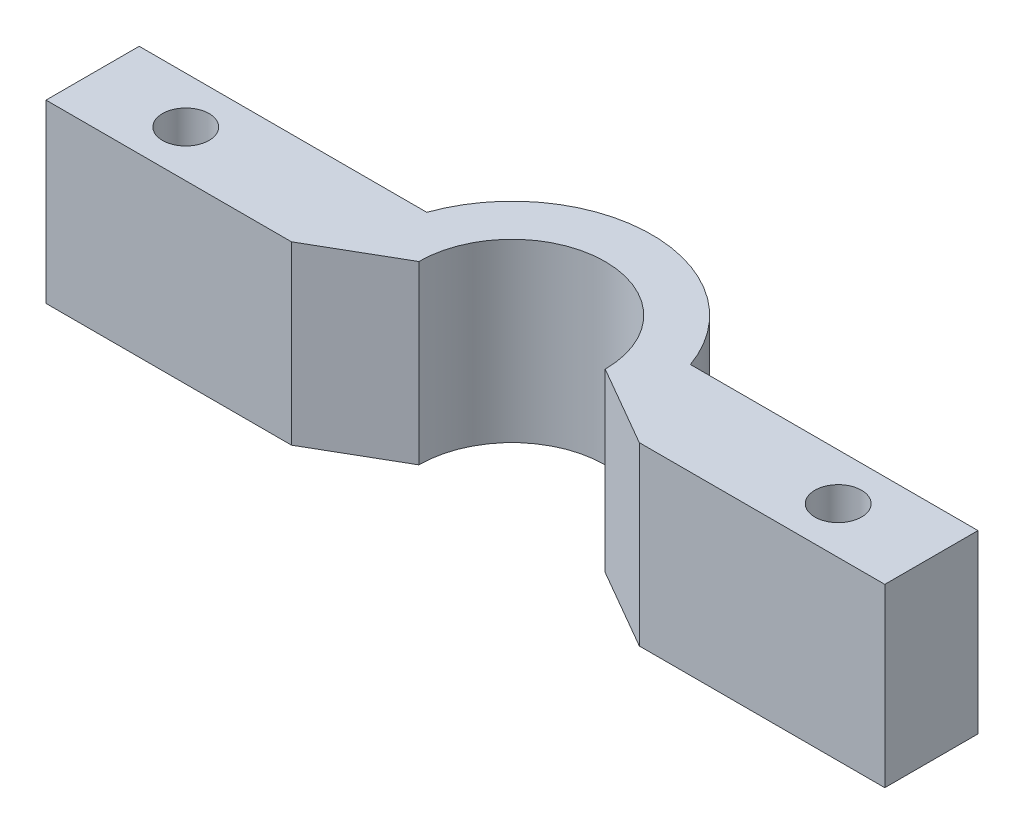
from build123d import *

# Parameters (mm, degrees)
SKETCH1_R           = 0.79375
BOSS_EXTRUDE1_DEPTH = 3


with BuildPart() as part:
    # Sketch1 → Boss-Extrude1 (new body, symmetric)
    with BuildSketch(Plane(origin=(0, 0, 0), x_dir=(1, 0, 0), z_dir=(0, 1, 0))):
        with BuildLine():
            ThreePointArc((-4.682314967, -0.870248702), (-4.742411374, -0.436967517), (-4.7625, 0))
            ThreePointArc((-4.7625, 0), (-4.69391314, 0.805348174), (-4.490128061, 1.5875))
            Line((-4.490128061, 1.5875), (-14.2875, 1.5875))
            Line((-14.2875, 1.5875), (-14.2875, -1.5875))
            Line((-14.2875, -1.5875), (-5.924630657, -1.5875))
            Line((-5.924630657, -1.5875), (-4.682314967, -0.870248702))
        make_face()
        with Locations((-11.1125, 0)):
            Circle(SKETCH1_R, mode=Mode.SUBTRACT)
        with BuildLine():
            Line((-4.7625, 0), (-3.175, 0))
            ThreePointArc((-3.175, 0), (-3.066814498, 0.821750468), (-2.749630657, 1.5875))
            Line((-2.749630657, 1.5875), (-4.490128061, 1.5875))
            ThreePointArc((-4.490128061, 1.5875), (-4.69391314, 0.805348174), (-4.7625, 0))
        make_face()
        with BuildLine():
            ThreePointArc((-2.749630657, 1.5875), (0, 3.175), (2.749630657, 1.5875))
            Line((2.749630657, 1.5875), (4.490128061, 1.5875))
            ThreePointArc((4.490128061, 1.5875), (0, 4.7625), (-4.490128061, 1.5875))
            Line((-4.490128061, 1.5875), (-2.749630657, 1.5875))
        make_face()
        with BuildLine():
            ThreePointArc((2.749630657, 1.5875), (3.066814498, 0.821750468), (3.175, 0))
            Line((3.175, 0), (4.7625, 0))
            ThreePointArc((4.7625, 0), (4.69391314, 0.805348174), (4.490128061, 1.5875))
            Line((4.490128061, 1.5875), (2.749630657, 1.5875))
        make_face()
        with BuildLine():
            ThreePointArc((4.490128061, 1.5875), (4.69391314, 0.805348174), (4.7625, 0))
            ThreePointArc((4.7625, 0), (4.742411374, -0.436967517), (4.682314967, -0.870248702))
            Line((4.682314967, -0.870248702), (5.924630657, -1.5875))
            Line((5.924630657, -1.5875), (14.2875, -1.5875))
            Line((14.2875, -1.5875), (14.2875, 1.5875))
            Line((14.2875, 1.5875), (4.490128061, 1.5875))
        make_face()
        with Locations((11.1125, 0)):
            Circle(SKETCH1_R, mode=Mode.SUBTRACT)
        with BuildLine():
            Line((-4.682314967, -0.870248702), (-3.175, 0))
            Line((-3.175, 0), (-4.7625, 0))
            ThreePointArc((-4.7625, 0), (-4.742411374, -0.436967517), (-4.682314967, -0.870248702))
        make_face()
        with BuildLine():
            Line((4.7625, 0), (3.175, 0))
            Line((3.175, 0), (4.682314967, -0.870248702))
            ThreePointArc((4.682314967, -0.870248702), (4.742411374, -0.436967517), (4.7625, 0))
        make_face()
    extrude(amount=BOSS_EXTRUDE1_DEPTH, both=True)


solid = part.part
